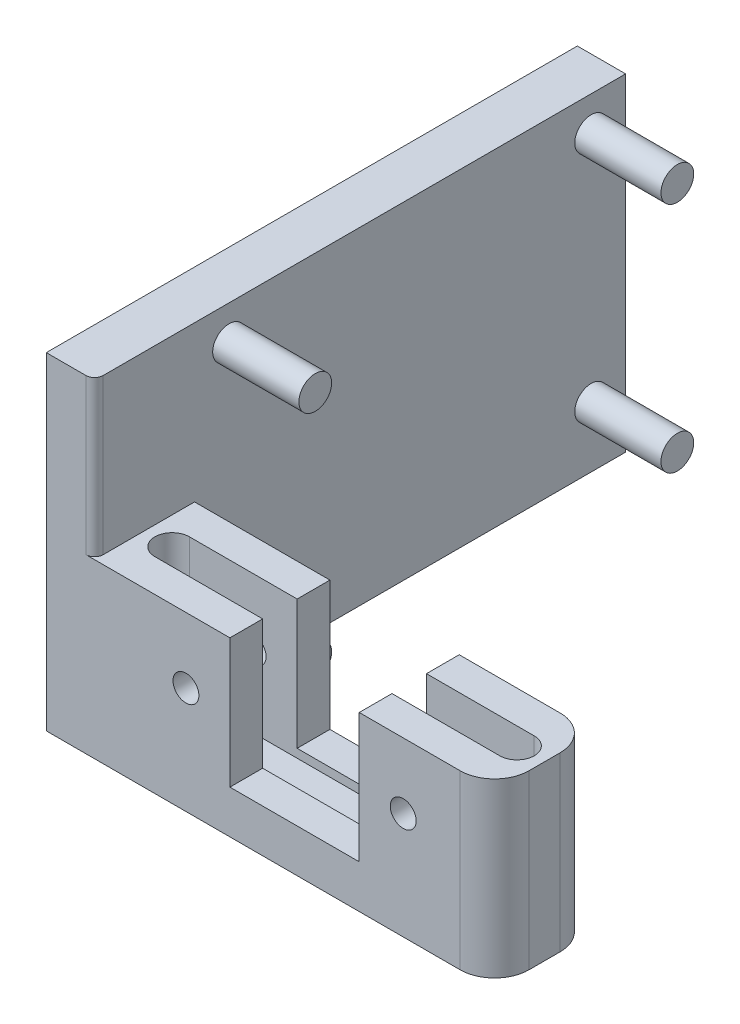
from build123d import *

# Parameters (mm, degrees)
EXTRUDE_1_DEPTH     = 19
SKETCH_3_W          = 23.2
SKETCH_3_H          = 9
CUT_EXTRUDE_2_DEPTH = 31.8
CUT_EXTRUDE_3_DEPTH = 8
SKETCH_5_W          = 7.5
SKETCH_5_H          = 7.5
CUT_EXTRUDE_4_DEPTH = 31.8
SKETCH_7_R          = 0.75
CUT_EXTRUDE_6_DEPTH = 31.8
FILLET_3_R          = 2
FILLET_4_R          = 0.5
SKETCH_8_R          = 0.95
EXTRUDE_2_DEPTH     = 5


with BuildPart() as part:
    # 草图1 → 凸台-拉伸1 (new body)
    with BuildSketch(Plane(origin=(0, 0, 0), x_dir=(1, 0, 0), z_dir=(0, 1, 0))):
        Polygon((-5.22, 18.4025), (-2.42, 18.4025), (-2.42, -6.5975), (20.78, -6.5975), (20.78, -12.3975), (-5.22, -12.3975), align=None)
    extrude(amount=EXTRUDE_1_DEPTH)

    # 草图3 → 切除-拉伸2 (cut, through all)
    with BuildSketch(Plane.XY.offset(12.3975)):
        with Locations((9.18, 14.5)):
            Rectangle(SKETCH_3_W, SKETCH_3_H)
    extrude(amount=-CUT_EXTRUDE_2_DEPTH, mode=Mode.SUBTRACT)

    # 草图4 → 切除-拉伸3 (cut)
    with BuildSketch(Plane(origin=(0, 10, 0), x_dir=(1, 0, 0), z_dir=(0, 1, 0))):
        with BuildLine():
            Line((-0.82, -8.4975), (19.18, -8.4975))
            ThreePointArc((19.18, -8.4975), (20.18, -9.4975), (19.18, -10.4975))
            Line((19.18, -10.4975), (-0.82, -10.4975))
            ThreePointArc((-0.82, -10.4975), (-1.82, -9.4975), (-0.82, -8.4975))
        make_face()
    extrude(amount=-CUT_EXTRUDE_3_DEPTH, mode=Mode.SUBTRACT)

    # 草图5 → 切除-拉伸4 (cut, through all)
    with BuildSketch(Plane.XY.offset(12.3975)):
        with Locations((9.18, 6.25)):
            Rectangle(SKETCH_5_W, SKETCH_5_H)
    extrude(amount=-CUT_EXTRUDE_4_DEPTH, mode=Mode.SUBTRACT)

    # 草图7 → 切除-拉伸6 (cut, through all)
    with BuildSketch(Plane.XY.offset(12.3975)):
        with Locations((2.88, 6.2)):
            Circle(SKETCH_7_R)
        with Locations((15.48, 6.2)):
            Circle(SKETCH_7_R)
    extrude(amount=-CUT_EXTRUDE_6_DEPTH, mode=Mode.SUBTRACT)

    # 圆角3
    fillet_3_edges = [part.edges().sort_by_distance(p)[0] for p in [
        (20.78, 5, 6.5975),
        (20.78, 5, 12.3975),
    ]]
    fillet(fillet_3_edges, radius=FILLET_3_R)

    # 圆角4
    fillet_4_edges = [part.edges().sort_by_distance(p)[0] for p in [
        (-2.42, 14.5, 12.3975),
    ]]
    fillet(fillet_4_edges, radius=FILLET_4_R)

    # 草图8 → 凸台-拉伸2 (add)
    with BuildSketch(Plane(origin=(-2.42, 0, 0), x_dir=(0, 0, -1), z_dir=(1, 0, 0))):
        with Locations((16.4025, 17)):
            Circle(SKETCH_8_R)
        with Locations((16.4025, 3.5)):
            Circle(SKETCH_8_R)
        with Locations((-4.5975, 3.5)):
            Circle(SKETCH_8_R)
        with Locations((-4.5975, 17)):
            Circle(SKETCH_8_R)
    extrude(amount=EXTRUDE_2_DEPTH)


solid = part.part
